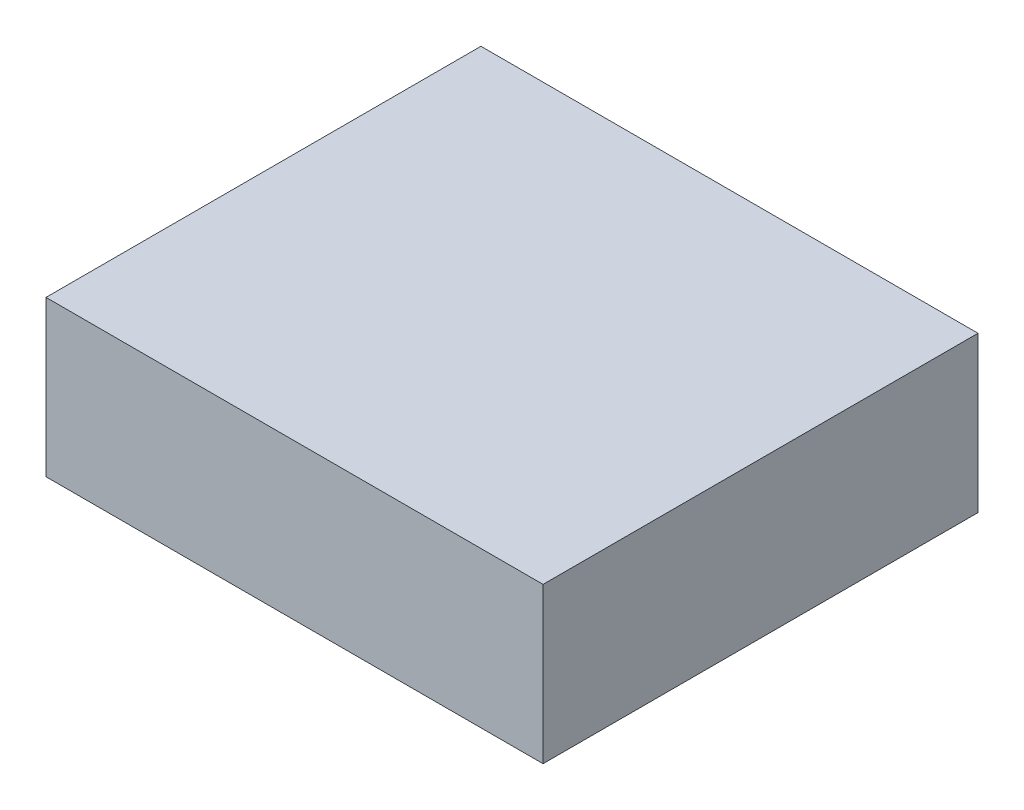
from build123d import *

# Parameters (mm, degrees)
SKETCH1_W           = 10.16
SKETCH1_H           = 3.175
BOSS_EXTRUDE1_DEPTH = 4.445
SKETCH3_OUTSIDE_W   = 14.934
SKETCH3_OUTSIDE_H   = 13.664
SKETCH3_OUTSIDE_W_2 = 10.16
SKETCH3_OUTSIDE_H_2 = 8.89
SKETCH3_OUTSIDE_W_3 = 5.08
SKETCH3_OUTSIDE_H_3 = 5.08
CUT_EXTRUDE1_DEPTH  = 1.905


with BuildPart() as part:
    # Sketch1 → Boss-Extrude1 (new body, symmetric)
    with BuildSketch(Plane.XY):
        with Locations((0, -1.5875)):
            Rectangle(SKETCH1_W, SKETCH1_H)
    extrude(amount=BOSS_EXTRUDE1_DEPTH, both=True)

    # Sketch3 outside → Cut-Extrude1 (cut)
    with BuildSketch(Plane.XZ.offset(3.175)):
        Rectangle(SKETCH3_OUTSIDE_W, SKETCH3_OUTSIDE_H)
        Rectangle(SKETCH3_OUTSIDE_W_2, SKETCH3_OUTSIDE_H_2, mode=Mode.SUBTRACT)
        Rectangle(SKETCH3_OUTSIDE_W_3, SKETCH3_OUTSIDE_H_3)
    extrude(amount=-CUT_EXTRUDE1_DEPTH, mode=Mode.SUBTRACT)


solid = part.part
